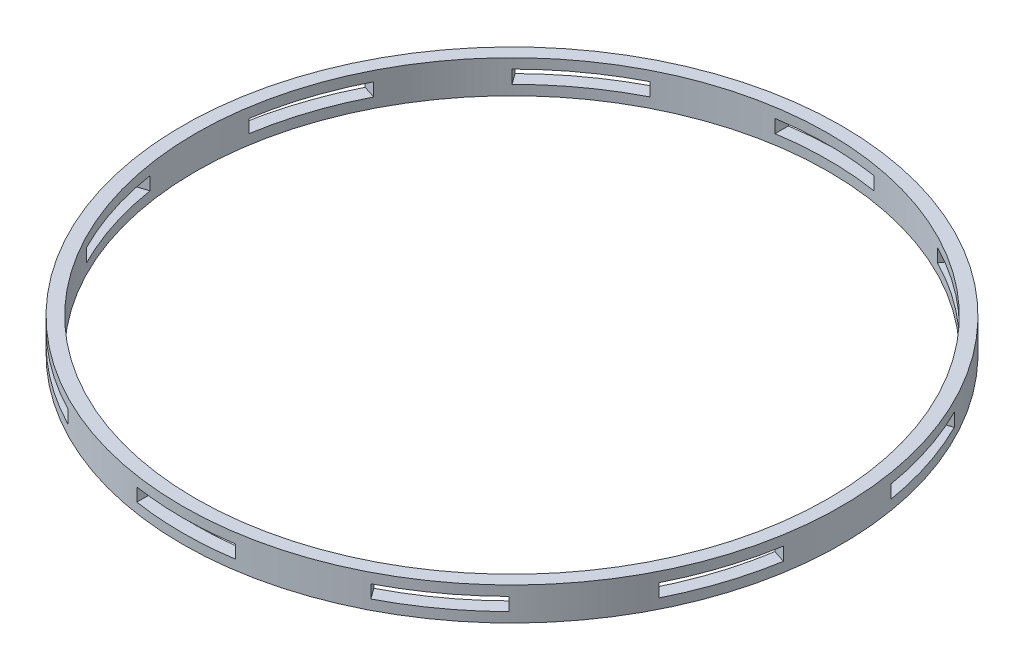
from build123d import *

# Parameters (mm, degrees)
SKETCH1_R           = 100
SKETCH1_R_2         = 96
BOSS_EXTRUDE1_DEPTH = 10
SKETCH2_W           = 30
SKETCH2_H           = 4
CUT_EXTRUDE1_DEPTH  = 142.774468788
CIRPATTERN1_COUNT   = 10


with BuildPart() as part:
    # Sketch1 → Boss-Extrude1 (new body)
    with BuildSketch(Plane(origin=(0, 0, 0), x_dir=(1, 0, 0), z_dir=(0, 1, 0))):
        Circle(SKETCH1_R)
        Circle(SKETCH1_R_2, mode=Mode.SUBTRACT)
    extrude(amount=BOSS_EXTRUDE1_DEPTH)

    # Sketch2 → Cut-Extrude1 (cut, through all)
    with BuildSketch(Plane.XY):
        with Locations((0, 5)):
            Rectangle(SKETCH2_W, SKETCH2_H)
    cut_extrude1 = extrude(amount=-CUT_EXTRUDE1_DEPTH, mode=Mode.SUBTRACT)

    # CirPattern1: Cut-Extrude1 ×10 about axis
    cirpattern1_axis = Axis((0, 10, 0), (0, -1, 0))
    for i in range(1, CIRPATTERN1_COUNT):
        add(cut_extrude1.rotate(cirpattern1_axis, i * 360 / CIRPATTERN1_COUNT), mode=Mode.SUBTRACT)


solid = part.part
